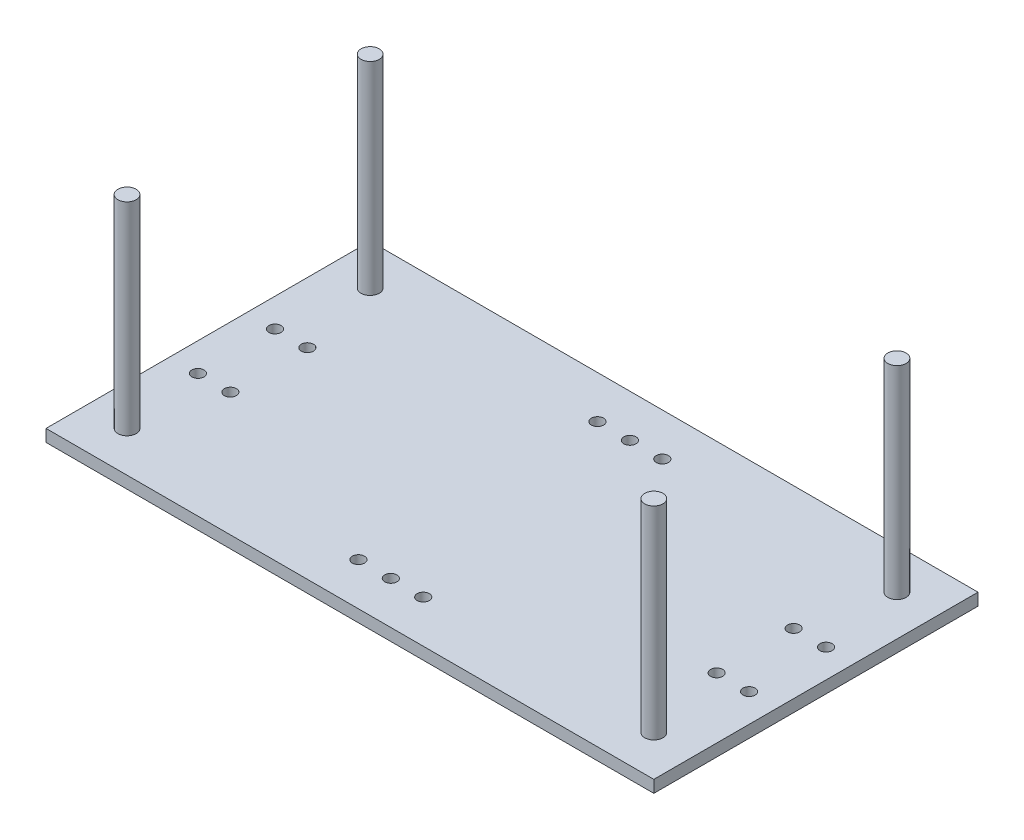
from build123d import *

# Parameters (mm, degrees)
SKETCH2_W           = 150
SKETCH2_H           = 80
SKETCH2_R           = 1.5
BOSS_EXTRUDE1_DEPTH = 3
SKETCH3_R           = 2.25
BOSS_EXTRUDE2_DEPTH = 50
SKETCH4_R           = 1.5
CUT_EXTRUDE1_DEPTH  = 10


with BuildPart() as part:
    # Sketch2 → Boss-Extrude1 (new body)
    with BuildSketch(Plane(origin=(0, 0, 0), x_dir=(1, 0, 0), z_dir=(0, 1, 0))):
        with Locations((-8.46473029, 1.825726141)):
            Rectangle(SKETCH2_W, SKETCH2_H)
        with Locations((-68.46473029, 11.325726141)):
            Circle(SKETCH2_R, mode=Mode.SUBTRACT)
        with Locations((-68.46473029, -7.674273859)):
            Circle(SKETCH2_R, mode=Mode.SUBTRACT)
        with Locations((-76.46473029, 11.325726141)):
            Circle(SKETCH2_R, mode=Mode.SUBTRACT)
        with Locations((-76.46473029, -7.674273859)):
            Circle(SKETCH2_R, mode=Mode.SUBTRACT)
        with Locations((51.53526971, -7.674273859)):
            Circle(SKETCH2_R, mode=Mode.SUBTRACT)
        with Locations((59.53526971, -7.674273859)):
            Circle(SKETCH2_R, mode=Mode.SUBTRACT)
        with Locations((59.53526971, 11.325726141)):
            Circle(SKETCH2_R, mode=Mode.SUBTRACT)
        with Locations((51.53526971, 11.325726141)):
            Circle(SKETCH2_R, mode=Mode.SUBTRACT)
    extrude(amount=-BOSS_EXTRUDE1_DEPTH)

    # Sketch3 → Boss-Extrude2 (add)
    with BuildSketch(Plane(origin=(0, 0, 0), x_dir=(1, 0, 0), z_dir=(0, 1, 0))):
        with Locations((56.53526971, 31.825726141)):
            Circle(SKETCH3_R)
        with Locations((56.53526971, -28.174273859)):
            Circle(SKETCH3_R)
        with Locations((-73.46473029, -28.174273859)):
            Circle(SKETCH3_R)
        with Locations((-73.46473029, 31.825726141)):
            Circle(SKETCH3_R)
    extrude(amount=BOSS_EXTRUDE2_DEPTH)

    # Sketch4 → Cut-Extrude1 (cut)
    with BuildSketch(Plane(origin=(0, -3, 0), x_dir=(-1, 0, 0), z_dir=(0, -1, 0))):
        with Locations((16.867382004, 31.325726141)):
            Circle(SKETCH4_R)
        with Locations((8.867382004, 31.325726141)):
            Circle(SKETCH4_R)
        with Locations((0.867382004, 31.325726141)):
            Circle(SKETCH4_R)
        with Locations((16.867382004, -27.674273859)):
            Circle(SKETCH4_R)
        with Locations((8.867382004, -27.674273859)):
            Circle(SKETCH4_R)
        with Locations((0.867382004, -27.674273859)):
            Circle(SKETCH4_R)
    extrude(amount=-CUT_EXTRUDE1_DEPTH, mode=Mode.SUBTRACT)


solid = part.part
